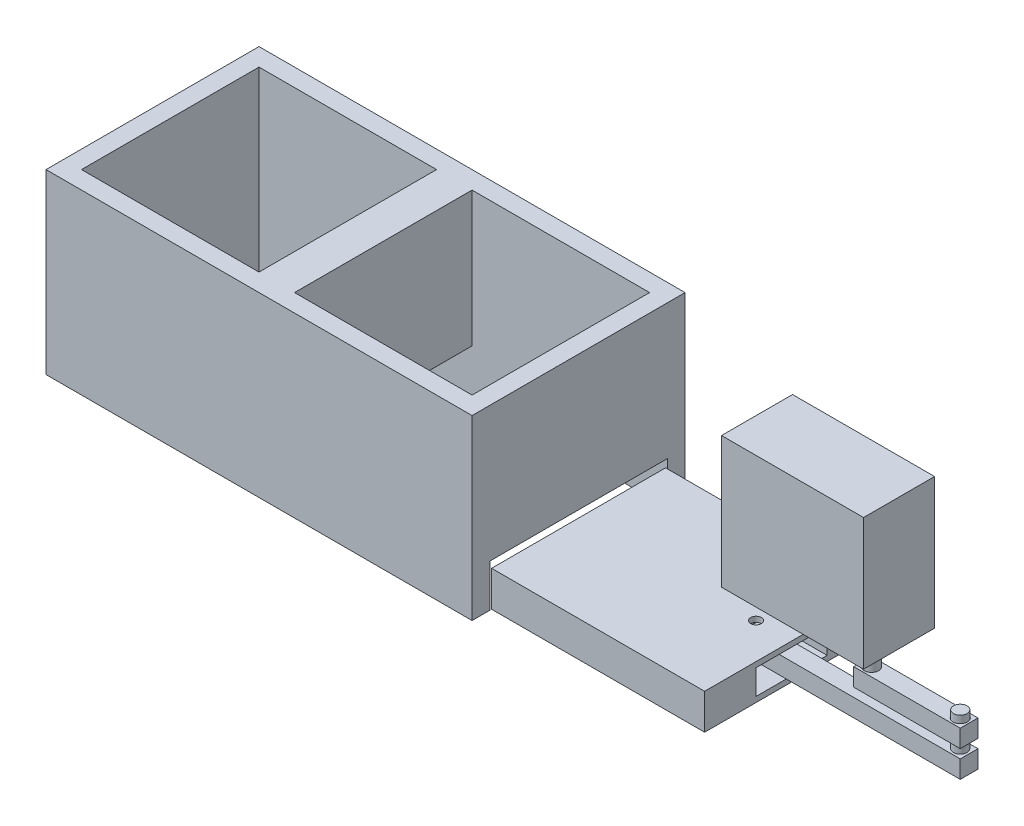
from build123d import *

# Parameters (mm, degrees)
SKETCH_1_W                = 60
SKETCH_1_H                = 60
EXTRUDE_1_DEPTH           = 50
SKETCH_2_W                = 50
SKETCH_2_H                = 50
CUT_EXTRUDE_1_DEPTH       = 51
SKETCH_3_W                = 50
SKETCH_3_H                = 12
CUT_EXTRUDE_2_DEPTH       = 10
SKETCH_4_W                = 50
SKETCH_4_H                = 12
CUT_EXTRUDE_3_DEPTH       = 10
SKETCH_6_W                = 60
SKETCH_6_H                = 50
EXTRUDE_2_DEPTH           = 10
SKETCH_8_W                = 1
SKETCH_8_H                = 10
CUT_EXTRUDE_5_DEPTH       = 60
SKETCH_13_W               = 14
SKETCH_13_H               = 7
CUT_EXTRUDE_6_DEPTH       = 12
SKETCH_14_W               = 5
SKETCH_14_H               = 5
EXTRUDE_4_DEPTH           = 62
SKETCH_15_W               = 3
SKETCH_15_H               = 7
CUT_EXTRUDE_7_DEPTH       = 12
SKETCH_16_W               = 3
SKETCH_16_H               = 7
CUT_EXTRUDE_8_DEPTH       = 12
SKETCH_18_W               = 30
SKETCH_18_H               = 5
EXTRUDE_5_DEPTH           = 5
SKETCH_19_R               = 2.002523802
CUT_EXTRUDE_9_DEPTH       = 5
SKETCH_20_R               = 1.5
CUT_EXTRUDE_10_DEPTH      = 41
CUT_EXTRUDE_10_DEPTH_BACK = 11
SKETCH_21_R               = 1.9046057
EXTRUDE_6_DEPTH           = 2
EXTRUDE_6_DEPTH_BACK      = 8
SKETCH_22_R               = 2
EXTRUDE_7_DEPTH           = 8
SKETCH_23_W               = 40
SKETCH_23_H               = 20
EXTRUDE_8_DEPTH           = 37


with BuildPart() as part:
    # 草图1 → 凸台-拉伸1 (new body)
    with BuildSketch(Plane(origin=(0, 0, 0), x_dir=(1, 0, 0), z_dir=(0, 1, 0))):
        Rectangle(SKETCH_1_W, SKETCH_1_H)
    extrude_1 = extrude(amount=EXTRUDE_1_DEPTH)

    # 草图2 → 切除-拉伸1 (cut, through all)
    with BuildSketch(Plane.XZ):
        Rectangle(SKETCH_2_W, SKETCH_2_H)
    cut_extrude_1 = extrude(amount=-CUT_EXTRUDE_1_DEPTH, mode=Mode.SUBTRACT)

    # 草图3 → 切除-拉伸2 (cut)
    with BuildSketch(Plane(origin=(30, 0, 0), x_dir=(0, 0, -1), z_dir=(1, 0, 0))):
        with Locations((0, 6)):
            Rectangle(SKETCH_3_W, SKETCH_3_H)
    cut_extrude_2 = extrude(amount=-CUT_EXTRUDE_2_DEPTH, mode=Mode.SUBTRACT)

    # 镜向3: 凸台-拉伸1, 切除-拉伸1, 切除-拉伸2 across plane
    add(extrude_1.mirror(Plane(origin=(30, 50, -30), x_dir=(0, 0, 1), z_dir=(-1, 0, 0))))
    add(cut_extrude_1.mirror(Plane(origin=(30, 50, -30), x_dir=(0, 0, 1), z_dir=(-1, 0, 0))), mode=Mode.SUBTRACT)
    add(cut_extrude_2.mirror(Plane(origin=(30, 50, -30), x_dir=(0, 0, 1), z_dir=(-1, 0, 0))), mode=Mode.SUBTRACT)

    # 草图4 → 切除-拉伸3 (cut)
    with BuildSketch(Plane(origin=(90, 0, 0), x_dir=(0, 0, -1), z_dir=(1, 0, 0))):
        with Locations((0, 6)):
            Rectangle(SKETCH_4_W, SKETCH_4_H)
    extrude(amount=-CUT_EXTRUDE_3_DEPTH, mode=Mode.SUBTRACT)

    # 草图6 → 凸台-拉伸2 (add)
    with BuildSketch(Plane.XZ):
        with Locations((120, 0.5)):
            Rectangle(SKETCH_6_W, SKETCH_6_H)
    extrude(amount=-EXTRUDE_2_DEPTH)

    # 草图8 → 切除-拉伸5 (cut)
    with BuildSketch(Plane(origin=(150, 0, 0), x_dir=(0, 0, -1), z_dir=(1, 0, 0))):
        with Locations((-25, 5)):
            Rectangle(SKETCH_8_W, SKETCH_8_H)
    extrude(amount=-CUT_EXTRUDE_5_DEPTH, mode=Mode.SUBTRACT)

    # 草图13 → 切除-拉伸6 (cut)
    with BuildSketch(Plane(origin=(150, 0, 0), x_dir=(0, 0, -1), z_dir=(1, 0, 0))):
        with Locations((0, 5)):
            Rectangle(SKETCH_13_W, SKETCH_13_H)
    extrude(amount=-CUT_EXTRUDE_6_DEPTH, mode=Mode.SUBTRACT)

    # 草图14 → 凸台-拉伸4 (add)
    with BuildSketch(Plane(origin=(138, 0, 0), x_dir=(0, 0, -1), z_dir=(1, 0, 0))):
        with Locations((0, 5)):
            Rectangle(SKETCH_14_W, SKETCH_14_H)
    extrude(amount=EXTRUDE_4_DEPTH)

    # 草图15 → 切除-拉伸7 (cut)
    with BuildSketch(Plane(origin=(150, 0, 0), x_dir=(0, 0, -1), z_dir=(1, 0, 0))):
        with Locations((-8.5, 5)):
            Rectangle(SKETCH_15_W, SKETCH_15_H)
    extrude(amount=-CUT_EXTRUDE_7_DEPTH, mode=Mode.SUBTRACT)

    # 草图16 → 切除-拉伸8 (cut)
    with BuildSketch(Plane(origin=(150, 0, 0), x_dir=(0, 0, -1), z_dir=(1, 0, 0))):
        with Locations((8.5, 5)):
            Rectangle(SKETCH_16_W, SKETCH_16_H)
    extrude(amount=-CUT_EXTRUDE_8_DEPTH, mode=Mode.SUBTRACT)

    # 草图20 → 切除-拉伸10 (cut, two sides)
    with BuildSketch(Plane(origin=(0, 10, 0), x_dir=(1, 0, 0), z_dir=(0, 1, 0))) as cut_extrude_10_sk:
        with Locations((140, 0)):
            Circle(SKETCH_20_R)
    extrude(amount=CUT_EXTRUDE_10_DEPTH, mode=Mode.SUBTRACT)
    extrude(cut_extrude_10_sk.sketch, amount=-CUT_EXTRUDE_10_DEPTH_BACK, mode=Mode.SUBTRACT)

    # 草图21 → 凸台-拉伸6 (add, two sides)
    with BuildSketch(Plane(origin=(0, 15, 0), x_dir=(1, 0, 0), z_dir=(0, 1, 0))) as extrude_6_sk:
        with Locations((197.5, 0)):
            Circle(SKETCH_21_R)
    extrude(amount=EXTRUDE_6_DEPTH)
    extrude(extrude_6_sk.sketch, amount=-EXTRUDE_6_DEPTH_BACK)


with BuildPart() as body_2:
    # 草图18 → 凸台-拉伸5 (new body)
    with BuildSketch(Plane(origin=(0, 10, 0), x_dir=(1, 0, 0), z_dir=(0, 1, 0))):
        with Locations((185, 0)):
            Rectangle(SKETCH_18_W, SKETCH_18_H)
    extrude(amount=EXTRUDE_5_DEPTH)

    # 草图19 → 切除-拉伸9 (cut)
    with BuildSketch(Plane(origin=(0, 15, 0), x_dir=(1, 0, 0), z_dir=(0, 1, 0))):
        with Locations((197.5, 0)):
            Circle(SKETCH_19_R)
    extrude(amount=-CUT_EXTRUDE_9_DEPTH, mode=Mode.SUBTRACT)

    # 草图22 → 凸台-拉伸7 (add)
    with BuildSketch(Plane(origin=(0, 15, 0), x_dir=(1, 0, 0), z_dir=(0, 1, 0))):
        with Locations((172.5, 0)):
            Circle(SKETCH_22_R)
    extrude(amount=EXTRUDE_7_DEPTH)

    # 草图23 → 凸台-拉伸8 (add)
    with BuildSketch(Plane(origin=(0, 23, 0), x_dir=(1, 0, 0), z_dir=(0, 1, 0))):
        with Locations((160, 0.265830592)):
            Rectangle(SKETCH_23_W, SKETCH_23_H)
    extrude(amount=EXTRUDE_8_DEPTH)


solid = Compound([part.part, body_2.part])
